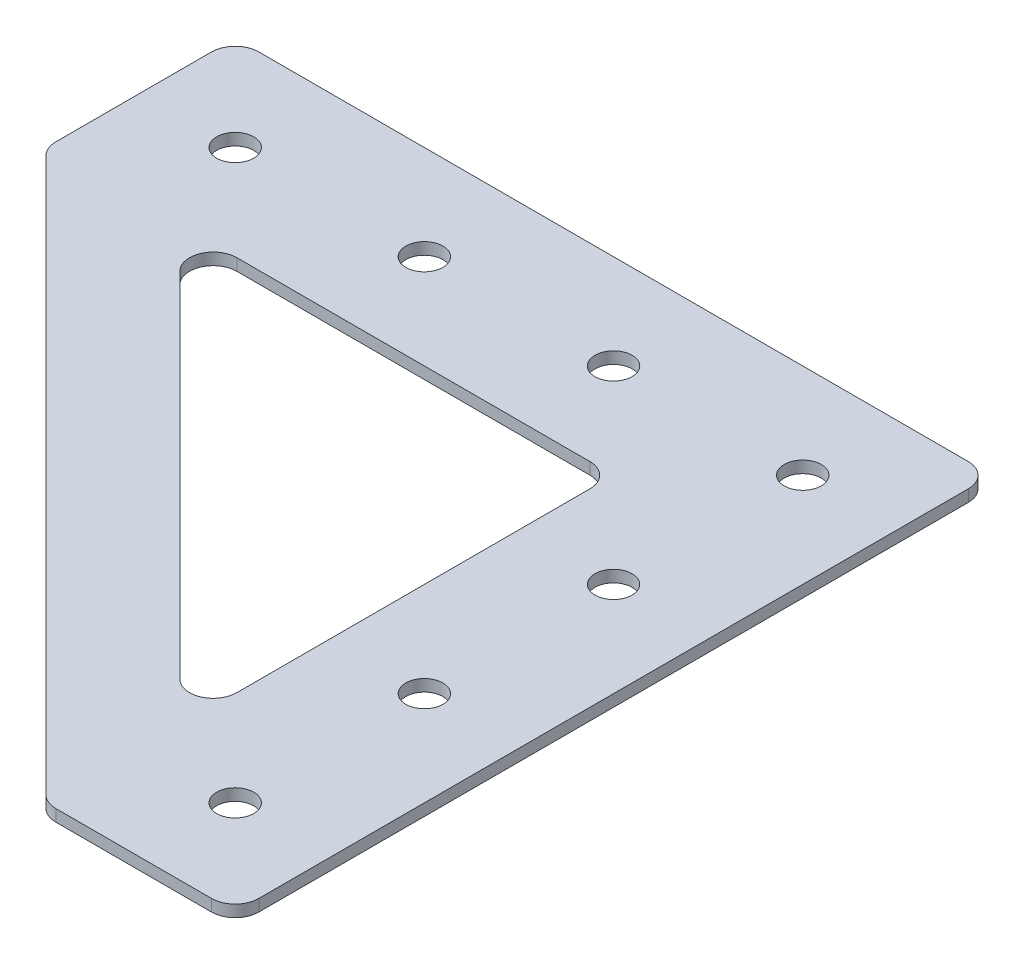
from build123d import *

# Parameters (mm, degrees)
BOSS_EXTRUDE1_DEPTH = 1.5875
SKETCH2_R           = 2.4892
CUT_EXTRUDE1_DEPTH  = 2.5875
LPATTERN1_COUNT     = 4
LPATTERN1_PITCH     = 25.4
LPATTERN1_COL_COUNT = 4
LPATTERN1_COL_PITCH = 25.4
FILLET1_R           = 3.175


with BuildPart() as part:
    # Sketch1 → Boss-Extrude1 (new body)
    with BuildSketch(Plane(origin=(0, 0, 0), x_dir=(1, 0, 0), z_dir=(0, 1, 0))):
        Polygon((0, 0), (-101.6, 0), (-101.6, -25.4), (-25.4, -101.6), (0, -101.6), align=None)
        Polygon((-25.4, -25.4), (-25.4, -83.639487758), (-83.639487758, -25.4), align=None, mode=Mode.SUBTRACT)
    extrude(amount=BOSS_EXTRUDE1_DEPTH)

    # Sketch2 → Cut-Extrude1 (cut, through all)
    with BuildSketch(Plane(origin=(0, 1.5875, 0), x_dir=(1, 0, 0), z_dir=(0, 1, 0))):
        with Locations((-12.7, -12.7)):
            Circle(SKETCH2_R)
    cut_extrude1 = extrude(amount=-CUT_EXTRUDE1_DEPTH, mode=Mode.SUBTRACT)

    # LPattern1: Cut-Extrude1 ×4
    with Locations(*[(0, 0, i * LPATTERN1_PITCH) for i in range(1, LPATTERN1_COUNT)]):
        add(cut_extrude1, mode=Mode.SUBTRACT)

    # LPattern1 col: Cut-Extrude1 ×4
    with Locations(*[(-i * LPATTERN1_COL_PITCH, 0, 0) for i in range(1, LPATTERN1_COL_COUNT)]):
        add(cut_extrude1, mode=Mode.SUBTRACT)

    # Fillet1
    fillet1_edges = [part.edges().sort_by_distance(p)[0] for p in [
        (-83.639487758, 0.79375, 25.4),
        (-25.4, 0.79375, 83.639487758),
        (-25.4, 0.79375, 25.4),
        (0, 0.79375, 101.6),
        (-25.4, 0.79375, 101.6),
        (-101.6, 0.79375, 25.4),
        (-101.6, 0.79375, 0),
        (0, 0.79375, 0),
    ]]
    fillet(fillet1_edges, radius=FILLET1_R)


solid = part.part
